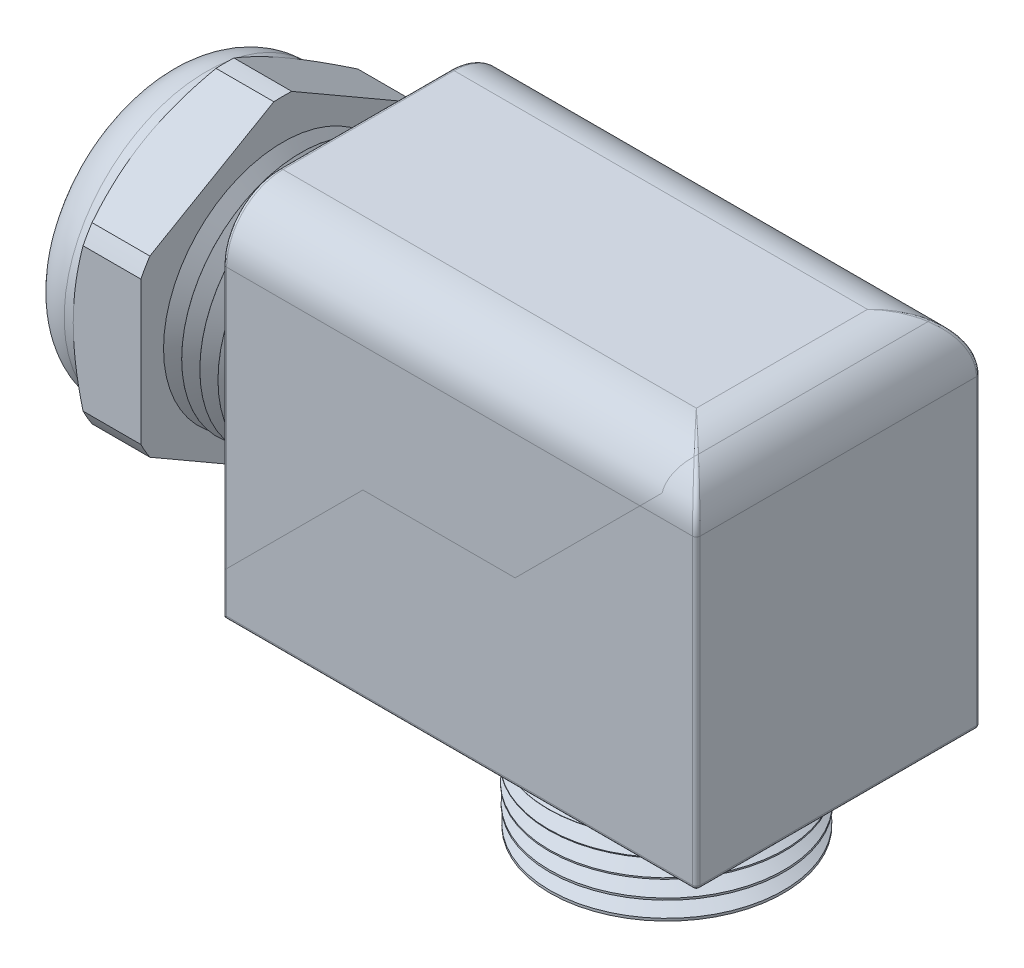
from build123d import *

# Parameters (mm, degrees)
SKETCH2_OUTSIDE_W          = 37.04
SKETCH2_OUTSIDE_H          = 37.04
CUT_EXTRUDE1_DEPTH         = 5.6896
SKETCH3_OUTSIDE_W          = 80.85
SKETCH3_OUTSIDE_H          = 83.716
SKETCH3_OUTSIDE_R          = 11.938
CUT_EXTRUDE2_DEPTH         = 13.577010526
CUT_EXTRUDE2_DRAFT         = -60
EXTRUDE3_REACH             = 13.938
EXTRUDE3_DIRECTION_2_REACH = 13.938
SKETCH19_W                 = 4.491789474
SKETCH19_H                 = 1.27
FILLET1_R                  = 3.729789474
EXTRUDE4_REACH             = 13.938
EXTRUDE4_DIRECTION_2_REACH = 13.938
FILLET4_R                  = 4.741333333
FILLET5_R                  = 0.321446328
SPLIT1_SURFACE_1_BACK      = 74.193
SPLIT1_SURFACE_1_DEPTH     = 148.386
SPLIT1_SURFACE_2_BACK      = 74.193
SPLIT1_SURFACE_2_DEPTH     = 148.386
SKETCH15_R                 = 5.969
SKETCH18_W                 = 3.729789474
SKETCH18_H                 = 2.0574
LPATTERN1_COUNT            = 5
LPATTERN1_PITCH            = 1.52654
LPATTERN2_COUNT            = 6
LPATTERN2_PITCH            = 1.52654
FILLET6_R                  = 0.254


with BuildPart() as part:
    # Sketch1 → Revolve1 (revolve)
    with BuildSketch(Plane.XY, mode=Mode.PRIVATE) as revolve1_sk:
        Polygon((-6.887410526, 10.033), (-6.887410526, 13.37056), (-12.577010526, 13.37056), (-12.577010526, 10.668), (-17.0688, 10.668), (-17.0688, 8.0264), (-12.577010526, 8.0264), (-12.577010526, 5.969), (0, 5.969), (0, 10.033), align=None)
    revolve(revolve1_sk.sketch.rotate(Axis((-18.386021217, 0, 0), (1, 0, 0)), 90), axis=Axis((-18.386021217, 0, 0), (1, 0, 0)))  # turned: the seam where the file's is

    # Sketch2 outside → Cut-Extrude1 (cut)
    with BuildSketch(Plane(origin=(-12.577010526, 0, 0), x_dir=(0, 0, -1), z_dir=(1, 0, 0))):
        Rectangle(SKETCH2_OUTSIDE_W, SKETCH2_OUTSIDE_H)
        with BuildLine():
            Line((11.938, -6.021298092), (11.938, 6.021298092))
            ThreePointArc((11.938, 6.021298092), (11.579244623, 6.68528), (11.183597111, 7.327962224))
            Line((11.183597111, 7.327962224), (0.754402889, 13.349260316))
            ThreePointArc((0.754402889, 13.349260316), (0, 13.37056), (-0.754402889, 13.349260316))
            Line((-0.754402889, 13.349260316), (-11.183597111, 7.327962224))
            ThreePointArc((-11.183597111, 7.327962224), (-11.579244623, 6.68528), (-11.938, 6.021298092))
            Line((-11.938, 6.021298092), (-11.938, -6.021298092))
            ThreePointArc((-11.938, -6.021298092), (-11.579244623, -6.68528), (-11.183597111, -7.327962224))
            Line((-11.183597111, -7.327962224), (-0.754402889, -13.349260316))
            ThreePointArc((-0.754402889, -13.349260316), (0, -13.37056), (0.754402889, -13.349260316))
            Line((0.754402889, -13.349260316), (11.183597111, -7.327962224))
            ThreePointArc((11.183597111, -7.327962224), (11.579244623, -6.68528), (11.938, -6.021298092))
        make_face(mode=Mode.SUBTRACT)
    extrude(amount=CUT_EXTRUDE1_DEPTH, mode=Mode.SUBTRACT)


with BuildPart() as cut_extrude2_tool:
    # Sketch3 outside → Cut-Extrude2 (with draft: the straight prism first)
    with BuildSketch(Plane.ZY.offset(12.577010526)):
        Rectangle(SKETCH3_OUTSIDE_W, SKETCH3_OUTSIDE_H)
        Circle(SKETCH3_OUTSIDE_R, mode=Mode.SUBTRACT)
    extrude(amount=-CUT_EXTRUDE2_DEPTH)
    # Cut-Extrude2: the draft: its side faces are tilted about the plane it starts from
    cut_extrude2_sides = [cut_extrude2_tool.faces().sort_by_distance(p)[0] for p in [
        (-5.788505263, -41.858, 0),
        (-5.788505263, 0, 40.425),
        (-5.788505263, 41.858, 0),
        (-5.788505263, 0, -40.425),
        (-5.788505263, 0, -11.938),
    ]]
    draft(cut_extrude2_sides, Plane.ZY.offset(12.577010526), CUT_EXTRUDE2_DRAFT)


with BuildPart() as part_1:
    add(part.part)

    # Cut-Extrude2: cut by cut_extrude2_tool
    add(cut_extrude2_tool.part, mode=Mode.SUBTRACT)

    # Extrude3: up to this face of the body (flat: up to its plane)
    extrude3_end = Plane(part_1.part.faces().sort_by_distance((-9.596925147, 0, 11.938))[0])
    # Sketch9 → Extrude3 (add, up to the picked face)
    with BuildSketch(Plane.XY, mode=Mode.PRIVATE) as extrude3_sk1:
        with BuildLine():
            Line((0, -11.7856), (0, 15.24))
            Line((0, 15.24), (39.8272, 15.24))
            ThreePointArc((39.8272, 15.24), (37.592114032, 14.314197079), (36.666311111, 12.079111111))
            Line((36.666311111, 12.079111111), (24.5872, 0))
            Line((24.5872, 0), (11.7856, 0))
            Line((11.7856, 0), (0, -11.7856))
        make_face()
    extrude3_tool1 = split(extrude(extrude3_sk1.sketch, amount=EXTRUDE3_REACH, mode=Mode.PRIVATE), bisect_by=extrude3_end, keep=Keep.BOTH, mode=Mode.PRIVATE)
    add(extrude3_tool1.solids().sort_by(Axis((14.739389, 6.678082, 0), (0, 0, 1)))[0])

    # Extrude3 direction 2: up to this face of the body (flat: up to its plane)
    extrude3_direction_2_end = Plane(part_1.part.faces().sort_by_distance((-9.596925147, 0, -11.938))[0])
    # Sketch9 → Extrude3 direction 2 (add, up to the picked face)
    with BuildSketch(Plane.XY, mode=Mode.PRIVATE) as extrude3_direction_2_sk1:
        with BuildLine():
            Line((0, -11.7856), (0, 15.24))
            Line((0, 15.24), (39.8272, 15.24))
            ThreePointArc((39.8272, 15.24), (37.592114032, 14.314197079), (36.666311111, 12.079111111))
            Line((36.666311111, 12.079111111), (24.5872, 0))
            Line((24.5872, 0), (11.7856, 0))
            Line((11.7856, 0), (0, -11.7856))
        make_face()
    extrude3_direction_2_tool1 = split(extrude(extrude3_direction_2_sk1.sketch, amount=-EXTRUDE3_DIRECTION_2_REACH, mode=Mode.PRIVATE), bisect_by=extrude3_direction_2_end, keep=Keep.BOTH, mode=Mode.PRIVATE)
    add(extrude3_direction_2_tool1.solids().sort_by(Axis((14.739389, 6.678082, 0), (0, 0, -1)))[0])

    # Sketch19 → Revolve5 (revolve)
    with BuildSketch(Plane.XY, mode=Mode.PRIVATE) as revolve5_sk:
        with Locations((-14.822905263, 11.303)):
            Rectangle(SKETCH19_W, SKETCH19_H)
    revolve(revolve5_sk.sketch.rotate(Axis((-18.386021217, 0, 0), (1, 0, 0)), 90), axis=Axis((-18.386021217, 0, 0), (1, 0, 0)))  # turned: the seam where the file's is

    # Fillet1
    fillet1_edges = [part_1.edges().sort_by_distance(p)[0] for p in [
        (-17.0688, 0, -11.938),
    ]]
    fillet(fillet1_edges, radius=FILLET1_R)

    # Extrude4: up to this face of the body (flat: up to its plane)
    extrude4_end = Plane(part_1.part.faces().sort_by_distance((14.739389246, 6.678082424, -11.938))[0])
    # Sketch10 → Extrude4 (add, up to the picked face)
    with BuildSketch(Plane.XY, mode=Mode.PRIVATE) as extrude4_sk1:
        with BuildLine():
            Line((39.8272, 15.24), (39.8272, -15.24))
            Line((39.8272, -15.24), (0, -15.24))
            Line((0, -15.24), (0, -11.7856))
            Line((0, -11.7856), (11.7856, 0))
            Line((11.7856, 0), (24.5872, 0))
            Line((24.5872, 0), (36.666311111, 12.079111111))
            ThreePointArc((36.666311111, 12.079111111), (37.592114032, 14.314197079), (39.8272, 15.24))
        make_face()
    extrude4_tool1 = split(extrude(extrude4_sk1.sketch, amount=-EXTRUDE4_REACH, mode=Mode.PRIVATE), bisect_by=extrude4_end, keep=Keep.BOTH, mode=Mode.PRIVATE)
    add(extrude4_tool1.solids().sort_by(Axis((24.307063, -5.670412, 0), (0, 0, -1)))[0])

    # Extrude4 direction 2: up to this face of the body (flat: up to its plane)
    extrude4_direction_2_end = Plane(part_1.part.faces().sort_by_distance((14.739389246, 6.678082424, 11.938))[0])
    # Sketch10 → Extrude4 direction 2 (add, up to the picked face)
    with BuildSketch(Plane.XY, mode=Mode.PRIVATE) as extrude4_direction_2_sk1:
        with BuildLine():
            Line((39.8272, 15.24), (39.8272, -15.24))
            Line((39.8272, -15.24), (0, -15.24))
            Line((0, -15.24), (0, -11.7856))
            Line((0, -11.7856), (11.7856, 0))
            Line((11.7856, 0), (24.5872, 0))
            Line((24.5872, 0), (36.666311111, 12.079111111))
            ThreePointArc((36.666311111, 12.079111111), (37.592114032, 14.314197079), (39.8272, 15.24))
        make_face()
    extrude4_direction_2_tool1 = split(extrude(extrude4_direction_2_sk1.sketch, amount=EXTRUDE4_DIRECTION_2_REACH, mode=Mode.PRIVATE), bisect_by=extrude4_direction_2_end, keep=Keep.BOTH, mode=Mode.PRIVATE)
    add(extrude4_direction_2_tool1.solids().sort_by(Axis((24.307063, -5.670412, 0), (0, 0, 1)))[0])

    # Fillet4
    fillet4_edges = [part_1.edges().sort_by_distance(p)[0] for p in [
        (19.9136, 15.24, 11.938),
        (39.8272, 15.24, 0),
        (19.9136, 15.24, -11.938),
    ]]
    fillet(fillet4_edges, radius=FILLET4_R)

    # Fillet5
    fillet5_edges = [part_1.edges().sort_by_distance(p)[0] for p in [
        (0, -2.370666667, 11.938),
        (0, -2.370666667, -11.938),
        (39.8272, -15.24, 0),
        (19.9136, -15.24, 11.938),
        (19.9136, -15.24, -11.938),
        (39.8272, -2.370666667, -11.938),
        (0, 15.24, 0),
        (0, 13.851295619, 10.549295619),
        (0, 13.851295619, -10.549295619),
        (39.8272, -2.370666667, 11.938),
        (38.148999886, 14.117707514, 10.259799886),
        (38.148999886, 14.117707514, -10.259799886),
    ]]
    fillet(fillet5_edges, radius=FILLET5_R)

    # Sketch11 → Revolve3 (revolve)
    with BuildSketch(Plane(origin=(0, -11.557, 0), x_dir=(1, 0, 0), z_dir=(0, 0, -1)), mode=Mode.PRIVATE) as revolve3_sk:
        Polygon((31.372946328, 3.683), (31.838851486, 12.573), (35.204153485, 12.573), (35.436946328, 3.683), align=None)
    revolve(revolve3_sk.sketch.rotate(Axis((25.403946328, 14.559320588, 0), (0, -1, 0)), 90), axis=Axis((25.403946328, 14.559320588, 0), (0, -1, 0)))  # turned: the seam where the file's is


with BuildPart() as body_2:
    # Split1: the piece behind the surface
    add(part_1.part)
    # Split1 surface: a surface, the sketch's curves swept straight by 148.386 mm
    with BuildLine(Plane.XY.offset(-SPLIT1_SURFACE_1_BACK), mode=Mode.PRIVATE) as split1_surface_1_path:
        Line((0, -11.7856), (11.7856, 0))
        Line((11.7856, 0), (24.5872, 0))
        Line((24.5872, 0), (36.666311111, 12.079111111))
        ThreePointArc((36.666311111, 12.079111111), (37.592114032, 14.314197079), (39.8272, 15.24))
    split1_surface_1 = Shell.extrude(split1_surface_1_path.wire(), (0 * SPLIT1_SURFACE_1_DEPTH, 0 * SPLIT1_SURFACE_1_DEPTH, 1 * SPLIT1_SURFACE_1_DEPTH))
    split(bisect_by=split1_surface_1, keep=Keep.BOTTOM)


with BuildPart() as part_2:
    add(part_1.part)

    # Split1: split by a surface, the side it looks to stays
    # Split1 surface: a surface, the sketch's curves swept straight by 148.386 mm
    with BuildLine(Plane.XY.offset(-SPLIT1_SURFACE_2_BACK), mode=Mode.PRIVATE) as split1_surface_2_path:
        Line((0, -11.7856), (11.7856, 0))
        Line((11.7856, 0), (24.5872, 0))
        Line((24.5872, 0), (36.666311111, 12.079111111))
        ThreePointArc((36.666311111, 12.079111111), (37.592114032, 14.314197079), (39.8272, 15.24))
    split1_surface_2 = Shell.extrude(split1_surface_2_path.wire(), (0 * SPLIT1_SURFACE_2_DEPTH, 0 * SPLIT1_SURFACE_2_DEPTH, 1 * SPLIT1_SURFACE_2_DEPTH))
    split(bisect_by=split1_surface_2, keep=Keep.TOP)


with BuildPart() as cut_sweep2_tool:
    # Cut-Sweep2: sweep along a path in Sketch14
    with BuildLine(Plane.XY) as cut_sweep2_path:
        Line((0, 0), (25.403946328, 0))
        Line((25.403946328, 0), (25.403946328, -24.13))
    # Sketch15 → Cut-Sweep2 (sweep)
    with BuildSketch(Plane(origin=(0, 0, 0), x_dir=(0, 0, -1), z_dir=(1, 0, 0))):
        Circle(SKETCH15_R)
    sweep(path=cut_sweep2_path.line, transition=Transition.RIGHT)


with BuildPart() as part_3:
    add(part_2.part)

    # Cut-Sweep2: cut by cut_sweep2_tool
    add(cut_sweep2_tool.part, mode=Mode.SUBTRACT)

    # Sketch16 → Cut-Revolve1 (revolve, cut)
    with BuildSketch(Plane.XY, mode=Mode.PRIVATE) as cut_revolve1_sk:
        Polygon((-6.887410526, 10.033), (-5.363411237, 10.033), (-6.125410882, 8.7131779), align=None)
    cut_revolve1 = revolve(cut_revolve1_sk.sketch.rotate(Axis((-30.631582976, 0, 0), (1, 0, 0)), 270), axis=Axis((-30.631582976, 0, 0), (1, 0, 0)), mode=Mode.SUBTRACT)  # turned: the seam where the file's is

    # LPattern1: Cut-Revolve1 ×5
    with Locations(*[(i * LPATTERN1_PITCH, 0, 0) for i in range(1, LPATTERN1_COUNT)]):
        add(cut_revolve1, mode=Mode.SUBTRACT)


with BuildPart() as body_2_1:
    add(body_2.part)

    # Cut-Sweep2: cut by cut_sweep2_tool
    add(cut_sweep2_tool.part, mode=Mode.SUBTRACT)

    # Sketch17 → Cut-Revolve2 (revolve, cut)
    with BuildSketch(Plane.XY, mode=Mode.PRIVATE) as cut_revolve2_sk:
        Polygon((15.387574388, -15.875), (15.42750452, -17.399870241), (16.72811582, -16.648961957), align=None)
    cut_revolve2 = revolve(cut_revolve2_sk.sketch.rotate(Axis((25.403946328, 20.529232597, 0), (0, -1, 0)), 270), axis=Axis((25.403946328, 20.529232597, 0), (0, -1, 0)), mode=Mode.SUBTRACT)  # turned: the seam where the file's is

    # LPattern2: Cut-Revolve2 ×6
    with Locations(*[(0, -i * LPATTERN2_PITCH, 0) for i in range(1, LPATTERN2_COUNT)]):
        add(cut_revolve2, mode=Mode.SUBTRACT)


with BuildPart() as body_3:
    # Sketch18 → Revolve4 (revolve)
    with BuildSketch(Plane.XY, mode=Mode.PRIVATE) as revolve4_sk:
        with Locations((-14.441905263, 6.9977)):
            Rectangle(SKETCH18_W, SKETCH18_H)
    revolve(revolve4_sk.sketch.rotate(Axis((7.498028318, 0, 0), (-1, 0, 0)), 90), axis=Axis((7.498028318, 0, 0), (-1, 0, 0)))  # turned: the seam where the file's is

    # Fillet6
    fillet6_edges = [body_3.edges().sort_by_distance(p)[0] for p in [
        (-16.3068, 0, 8.0264),
    ]]
    fillet(fillet6_edges, radius=FILLET6_R)


solid = Compound([part_3.part, body_2_1.part, body_3.part])
